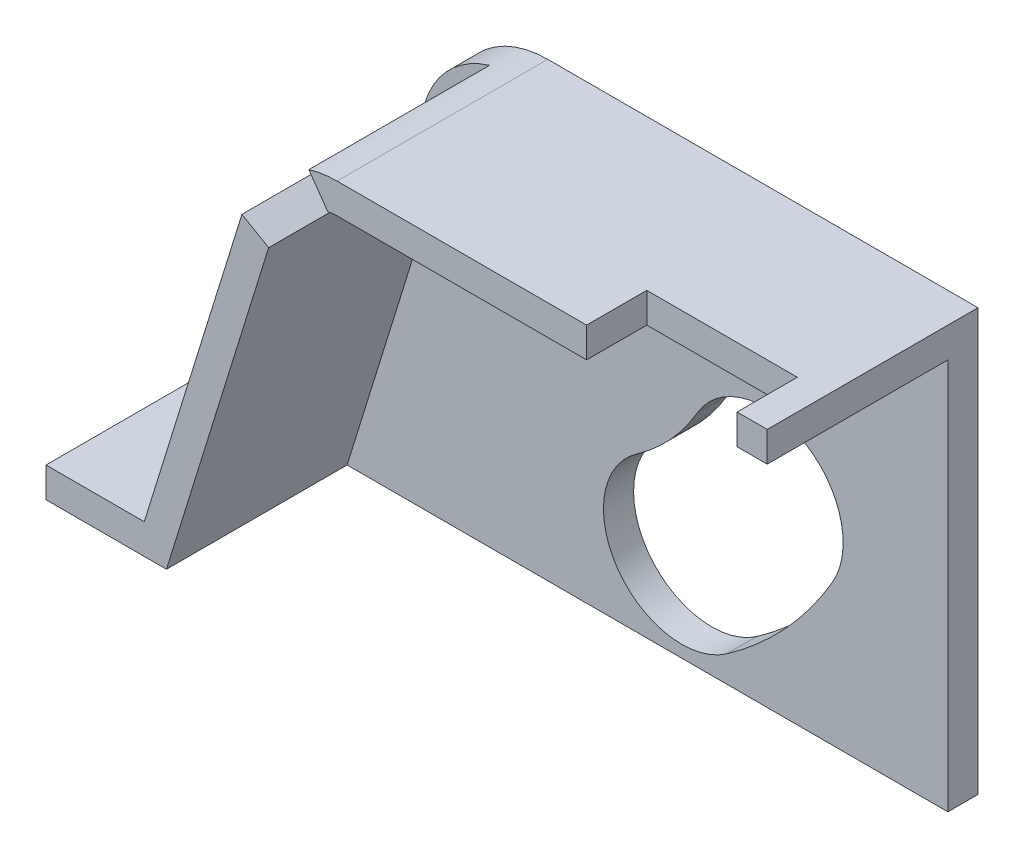
from build123d import *

# Parameters (mm, degrees)
SKETCH1_W           = 120
SKETCH1_H           = 100
BOSS_EXTRUDE1_DEPTH = 5
SKETCH2_R           = 2.5
CUT_EXTRUDE1_DEPTH  = 6
CUT_EXTRUDE3_DEPTH  = 10
BOSS_EXTRUDE3_DEPTH = 30
SKETCH8_W           = 20
SKETCH8_H           = 5
BOSS_EXTRUDE4_DEPTH = 35
SKETCH9_W           = 25
SKETCH9_H           = 10
CUT_EXTRUDE4_DEPTH  = 71
SKETCH10_W          = 35
SKETCH10_H          = 70
CUT_EXTRUDE5_DEPTH  = 120.765167123


with BuildPart() as part:
    # Sketch1 → Boss-Extrude1 (new body)
    with BuildSketch(Plane.XY):
        with Locations((60, 50)):
            Rectangle(SKETCH1_W, SKETCH1_H)
    boss_extrude1 = extrude(amount=BOSS_EXTRUDE1_DEPTH)

    # Sketch2 → Cut-Extrude1 (cut, through all)
    with BuildSketch(Plane.XY.offset(5)):
        with Locations((48.561388608, 53.909722104)):
            Circle(SKETCH2_R)
        with BuildLine():
            ThreePointArc((83.262763007, 4.351023424), (93.087143476, 12.949898455), (100.837944203, 23.456286582))
            ThreePointArc((100.837944203, 23.456286582), (96.148678733, 41.232978888), (78.371986427, 36.543713418))
            ThreePointArc((78.371986427, 36.543713418), (73.952108326, 30.552467296), (68.349775662, 25.648976576))
            ThreePointArc((68.349775662, 25.648976576), (65.157292759, 7.543506327), (83.262763007, 4.351023424))
        make_face()
    cut_extrude1 = extrude(amount=-CUT_EXTRUDE1_DEPTH, mode=Mode.SUBTRACT)

    # Sketch5 → Cut-Extrude3 (cut)
    with BuildSketch(Plane.XY.offset(5)):
        with BuildLine():
            Line((120, 70), (48.561388608, 70))
            ThreePointArc((48.561388608, 70), (39.016134462, 66.862913451), (33.192915272, 58.674915711))
            Line((33.192915272, 58.674915711), (15, 0))
            Line((15, 0), (0, 0))
            Line((0, 0), (0, 100))
            Line((0, 100), (120, 100))
            Line((120, 100), (120, 70))
        make_face()
    cut_extrude3 = extrude(amount=-CUT_EXTRUDE3_DEPTH, mode=Mode.SUBTRACT)

    # Sketch7 → Boss-Extrude3 (add)
    with BuildSketch(Plane(origin=(0, 0, 0), x_dir=(-1, 0, 0), z_dir=(0, 0, -1))):
        Polygon((-15, 0), (-32.773002065, 57.320631823), (-37.206950606, 54.737658166), (-20.234832877, 0), align=None)
        with BuildLine():
            Line((-120, 70), (-48.561388608, 70))
            ThreePointArc((-48.561388608, 70), (-46.197570118, 69.825418913), (-43.885046952, 69.305464096))
            Line((-43.885046952, 69.305464096), (-47.035737431, 64.805811769))
            ThreePointArc((-47.035737431, 64.805811769), (-47.792408669, 64.951257894), (-48.561388608, 65))
            Line((-48.561388608, 65), (-120, 65))
            Line((-120, 65), (-120, 70))
        make_face()
    boss_extrude3 = extrude(amount=BOSS_EXTRUDE3_DEPTH)

    # Sketch8 → Boss-Extrude4 (add, through all)
    with BuildSketch(Plane(origin=(0, 0, -30), x_dir=(-1, 0, 0), z_dir=(0, 0, -1))):
        with Locations((-10.234832877, 2.5)):
            Rectangle(SKETCH8_W, SKETCH8_H)
    boss_extrude4 = extrude(amount=-BOSS_EXTRUDE4_DEPTH)

    # Sketch9 → Cut-Extrude4 (cut, through all)
    with BuildSketch(Plane(origin=(0, 70, 0), x_dir=(1, 0, 0), z_dir=(0, 1, 0))):
        with Locations((102.5, 25)):
            Rectangle(SKETCH9_W, SKETCH9_H)
    cut_extrude4 = extrude(amount=-CUT_EXTRUDE4_DEPTH, mode=Mode.SUBTRACT)

    # Mirror1: Boss-Extrude1, Cut-Extrude1, Cut-Extrude3, Boss-Extrude3, Boss-Extrude4, Cut-Extrude4 across plane
    add(boss_extrude1.mirror(Plane(origin=(0, 0, 5), x_dir=(1, 0, 0), z_dir=(0, 0, -1))))
    add(cut_extrude1.mirror(Plane(origin=(0, 0, 5), x_dir=(1, 0, 0), z_dir=(0, 0, -1))), mode=Mode.SUBTRACT)
    add(cut_extrude3.mirror(Plane(origin=(0, 0, 5), x_dir=(1, 0, 0), z_dir=(0, 0, -1))), mode=Mode.SUBTRACT)
    add(boss_extrude3.mirror(Plane(origin=(0, 0, 5), x_dir=(1, 0, 0), z_dir=(0, 0, -1))))
    add(boss_extrude4.mirror(Plane(origin=(0, 0, 5), x_dir=(1, 0, 0), z_dir=(0, 0, -1))))
    add(cut_extrude4.mirror(Plane(origin=(0, 0, 5), x_dir=(1, 0, 0), z_dir=(0, 0, -1))), mode=Mode.SUBTRACT)

    # Sketch10 → Cut-Extrude5 (cut, through all)
    with BuildSketch(Plane(origin=(120, 0, 0), x_dir=(0, 0, -1), z_dir=(1, 0, 0))):
        with Locations((12.5, 35)):
            Rectangle(SKETCH10_W, SKETCH10_H)
    extrude(amount=-CUT_EXTRUDE5_DEPTH, mode=Mode.SUBTRACT)


solid = part.part
